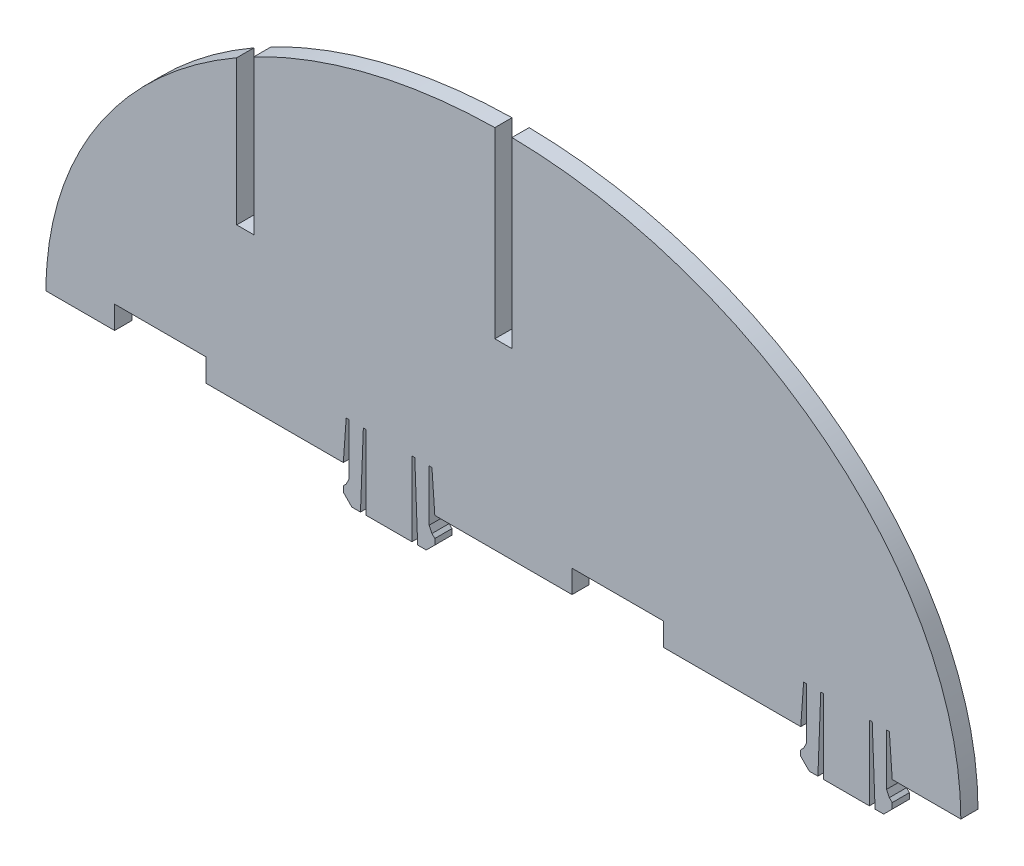
from build123d import *

# Parameters (mm, degrees)
BOSS_EXTRUDE1_DEPTH     = 3
CUT_EXTRUDE1_DEPTH      = 1.0000001
CUT_EXTRUDE1_DEPTH_BACK = 3
CUT_EXTRUDE2_DEPTH      = 1.0000001
CUT_EXTRUDE2_DEPTH_BACK = 3
CUT_EXTRUDE3_DEPTH      = 1.0000001
CUT_EXTRUDE3_DEPTH_BACK = 3
CUT_EXTRUDE4_DEPTH      = 1.0000001
CUT_EXTRUDE4_DEPTH_BACK = 3


with BuildPart() as part:
    # Sketch1 → Boss-Extrude1 (new body)
    with BuildSketch(Plane.XY):
        with BuildLine():
            Line((-80, 41.231056256), (-28, 41.231056256))
            Line((-28, 41.231056256), (-27.5, 48.233227348))
            Line((-27.5, 48.233227348), (-27, 48.233227348))
            Line((-27, 48.233227348), (-27, 39.233227348))
            Line((-27, 39.233227348), (-27.5, 38.233227348))
            Line((-27.5, 38.233227348), (-28, 37.733227348))
            Line((-28, 37.733227348), (-28, 36.733227348))
            Line((-28, 36.733227348), (-26.5, 35.233227348))
            Line((-26.5, 35.233227348), (-25, 35.233227348))
            Line((-25, 35.233227348), (-24.5, 48.233227348))
            Line((-24.5, 48.233227348), (-24, 48.233227348))
            Line((-24, 48.233227348), (-24, 35.233227348))
            Line((-24, 35.233227348), (-16, 35.233227348))
            Line((-16, 35.233227348), (-16, 48.233227348))
            Line((-16, 48.233227348), (-15.5, 48.233227348))
            Line((-15.5, 48.233227348), (-15, 35.233227348))
            Line((-15, 35.233227348), (-13.5, 35.233227348))
            Line((-13.5, 35.233227348), (-12, 36.733227348))
            Line((-12, 36.733227348), (-12, 37.733227348))
            Line((-12, 37.733227348), (-12.5, 38.233227348))
            Line((-12.5, 38.233227348), (-13, 39.233227348))
            Line((-13, 39.233227348), (-13, 48.233227348))
            Line((-13, 48.233227348), (-12.5, 48.233227348))
            Line((-12.5, 48.233227348), (-12, 41.231056256))
            Line((-12, 41.231056256), (52, 41.231056256))
            Line((52, 41.231056256), (52.5, 48.233227348))
            Line((52.5, 48.233227348), (53, 48.233227348))
            Line((53, 48.233227348), (53, 39.233227348))
            Line((53, 39.233227348), (52.5, 38.233227348))
            Line((52.5, 38.233227348), (52, 37.733227348))
            Line((52, 37.733227348), (52, 36.733227348))
            Line((52, 36.733227348), (53.5, 35.233227348))
            Line((53.5, 35.233227348), (55, 35.233227348))
            Line((55, 35.233227348), (55.5, 48.233227348))
            Line((55.5, 48.233227348), (56, 48.233227348))
            Line((56, 48.233227348), (56, 35.233227348))
            Line((56, 35.233227348), (64, 35.233227348))
            Line((64, 35.233227348), (64, 48.233227348))
            Line((64, 48.233227348), (64.5, 48.233227348))
            Line((64.5, 48.233227348), (65, 35.233227348))
            Line((65, 35.233227348), (66.5, 35.233227348))
            Line((66.5, 35.233227348), (68, 36.733227348))
            Line((68, 36.733227348), (68, 37.733227348))
            Line((68, 37.733227348), (67.5, 38.233227348))
            Line((67.5, 38.233227348), (67, 39.233227348))
            Line((67, 39.233227348), (67, 48.233227348))
            Line((67, 48.233227348), (67.5, 48.233227348))
            Line((67.5, 48.233227348), (68, 41.231056256))
            Line((68, 41.231056256), (80, 41.231056256))
            add(Edge.make_bspline(
                [(80, 41.231056256), (80, 105.23), (0, 105.23)],
                knots=[0, 0, 0, 1.570796327, 1.570796327, 1.570796327], degree=2, weights=[1, 0.707106781, 1]))
            add(Edge.make_bspline(
                [(0, 105.23), (-80, 105.23), (-80, 41.231056256)],
                knots=[1.570796327, 1.570796327, 1.570796327, 3.141592654, 3.141592654, 3.141592654], degree=2, weights=[1, 0.707106781, 1]))
        make_face()
    extrude(amount=BOSS_EXTRUDE1_DEPTH)

    # Sketch8 → Cut-Extrude1 (cut, two sides)
    with BuildSketch(Plane.XY.offset(3)) as cut_extrude1_sk:
        Polygon((-68, -291.258415465), (-68, 41.231056256), (-68, 45.231056256), (-52, 45.231056256), (-52, 41.231056256), (-52, -291.258415465), (-52, -956.237358907), (-68, -956.237358907), align=None)
    extrude(amount=CUT_EXTRUDE1_DEPTH, mode=Mode.SUBTRACT)
    extrude(cut_extrude1_sk.sketch, amount=-CUT_EXTRUDE1_DEPTH_BACK, mode=Mode.SUBTRACT)

    # Sketch9 → Cut-Extrude2 (cut, two sides)
    with BuildSketch(Plane.XY.offset(3)) as cut_extrude2_sk:
        Polygon((28, -219.845544284), (28, 41.231056256), (28, 45.231056256), (12, 45.231056256), (12, 41.231056256), (12, -219.845544284), (12, -741.998745365), (28, -741.998745365), align=None)
    extrude(amount=CUT_EXTRUDE2_DEPTH, mode=Mode.SUBTRACT)
    extrude(cut_extrude2_sk.sketch, amount=-CUT_EXTRUDE2_DEPTH_BACK, mode=Mode.SUBTRACT)

    # Sketch10 → Cut-Extrude3 (cut, two sides)
    with BuildSketch(Plane.XY.offset(3)) as cut_extrude3_sk:
        Polygon((-1.500000233, 330.069612224), (-1.500000233, 105.218749193), (-1.500000233, 73.231), (1.499999767, 73.231), (1.499999767, 105.2187492), (1.499999767, 330.069612231), (1.499998719, 779.771338291), (-1.500001281, 779.771338284), align=None)
    extrude(amount=CUT_EXTRUDE3_DEPTH, mode=Mode.SUBTRACT)
    extrude(cut_extrude3_sk.sketch, amount=-CUT_EXTRUDE3_DEPTH_BACK, mode=Mode.SUBTRACT)

    # Sketch11 → Cut-Extrude4 (cut, two sides)
    with BuildSketch(Plane.XY.offset(3)) as cut_extrude4_sk:
        Polygon((-46.64838896, 381.810733149), (-46.64838896, 93.22359963), (-46.64838896, 67.904187559), (-43.64838896, 67.904187559), (-43.64838896, 94.864894992), (-43.64838896, 383.452028511), (-320.670818857, 889.800434121), (-323.670818857, 888.159138759), align=None)
    extrude(amount=CUT_EXTRUDE4_DEPTH, mode=Mode.SUBTRACT)
    extrude(cut_extrude4_sk.sketch, amount=-CUT_EXTRUDE4_DEPTH_BACK, mode=Mode.SUBTRACT)


solid = part.part
